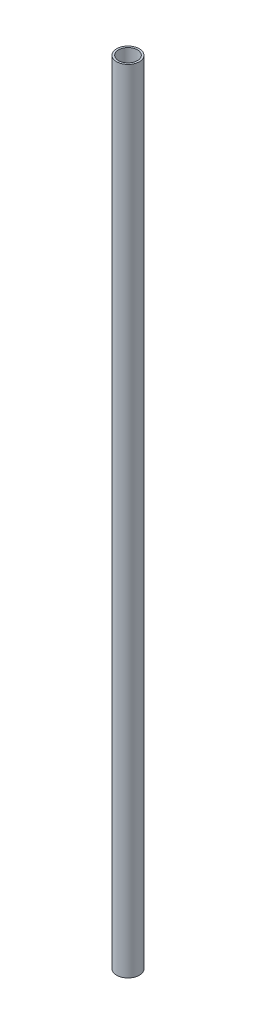
from build123d import *

# Parameters (mm, degrees)
SKETCH3_R           = 6
SKETCH3_R_2         = 5
BOSS_EXTRUDE2_DEPTH = 420


with BuildPart() as part:
    # Sketch3 → Boss-Extrude2 (new body)
    with BuildSketch(Plane(origin=(0, 0, -4.93715546), x_dir=(1, 0, 0), z_dir=(0, 1, 0))):
        with Locations((0, -4.93715546)):
            Circle(SKETCH3_R)
        with Locations((0, -4.93715546)):
            Circle(SKETCH3_R_2, mode=Mode.SUBTRACT)
    extrude(amount=BOSS_EXTRUDE2_DEPTH)


solid = part.part
